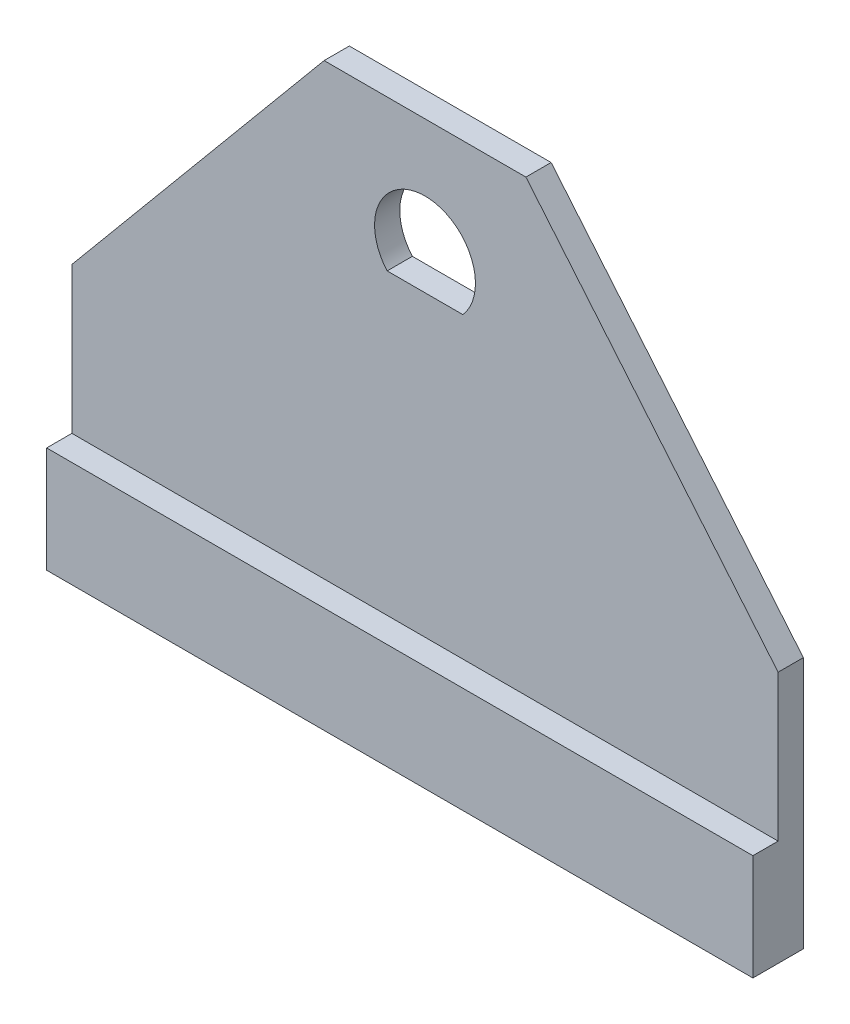
from build123d import *

# Parameters (mm, degrees)
BOSS_EXTRUDE1_START = -10
BOSS_EXTRUDE1_DEPTH = 5
SKETCH1_3_W         = 140
SKETCH1_3_H         = 21.000815728
BOSS_EXTRUDE2_DEPTH = 10


with BuildPart() as part:
    # Sketch1 → Boss-Extrude1 (new body)
    with BuildSketch(Plane.XY.offset(BOSS_EXTRUDE1_START)):
        Polygon((-149.564743262, -9.396609427), (-149.564743262, -38.395793699), (-9.564743262, -38.395793699), (-9.564743262, -9.396609427), (-59.564743262, 50.603390573), (-99.564743262, 50.603390573), align=None)
        with BuildLine():
            Line((-72.064743262, 20.743540142), (-87.064743262, 20.743540142))
            ThreePointArc((-87.064743262, 20.743540142), (-79.564743262, 37.357918419), (-72.064743262, 20.743540142))
        make_face(mode=Mode.SUBTRACT)
    extrude(amount=BOSS_EXTRUDE1_DEPTH)

    # Sketch1_3 → Boss-Extrude2 (add)
    with BuildSketch(Plane.XY):
        with Locations((-79.564743262, -48.896201563)):
            Rectangle(SKETCH1_3_W, SKETCH1_3_H)
    extrude(amount=-BOSS_EXTRUDE2_DEPTH)


solid = part.part
